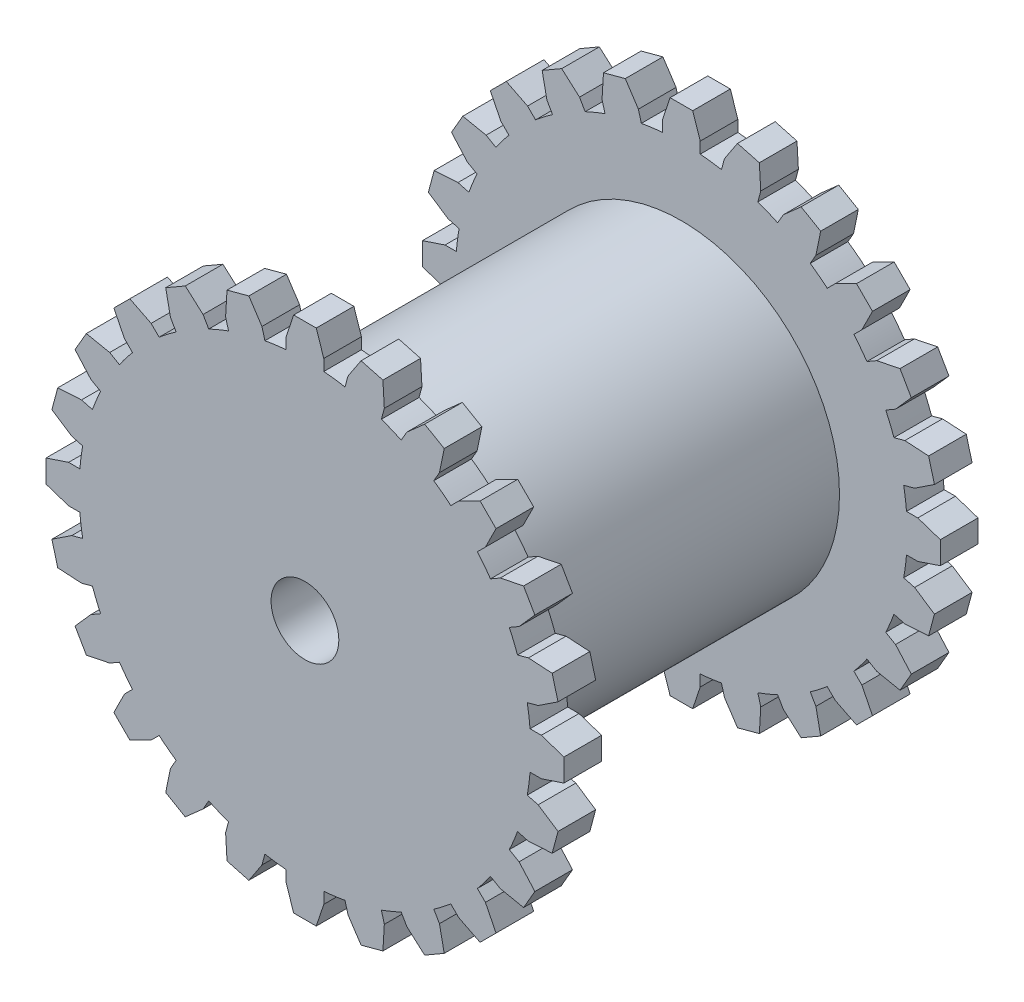
from build123d import *

# Parameters (mm, degrees)
SKETCH1_R           = 30
SKETCH1_R_2         = 4.5
BOSS_EXTRUDE1_DEPTH = 5
BOSS_EXTRUDE2_DEPTH = 5
CIRPATTERN1_COUNT   = 24
SKETCH3_R           = 21
SKETCH3_R_2         = 4.5
BOSS_EXTRUDE5_DEPTH = 22.5


with BuildPart() as part:
    # Sketch1 → Boss-Extrude1 (new body)
    with BuildSketch(Plane.XY):
        Circle(SKETCH1_R)
        Circle(SKETCH1_R_2, mode=Mode.SUBTRACT)
    extrude(amount=BOSS_EXTRUDE1_DEPTH)

    # Sketch2 → Boss-Extrude2 (add)
    with BuildSketch(Plane.XY):
        with BuildLine():
            Line((1.5, 34.395651858), (-1.5, 34.395651858))
            Line((-1.5, 34.395651858), (-2.5, 31.395651858))
            Line((-2.5, 31.395651858), (-2.5, 29.895651858))
            ThreePointArc((-2.5, 29.895651858), (0, 30), (2.5, 29.895651858))
            Line((2.5, 29.895651858), (2.5, 31.395651858))
            Line((2.5, 31.395651858), (1.5, 34.395651858))
        make_face()
    boss_extrude2 = extrude(amount=BOSS_EXTRUDE2_DEPTH)

    # CirPattern1: Boss-Extrude2 ×24 about axis
    cirpattern1_axis = Axis((0, 0, 0), (0, 0, 1))
    for i in range(1, CIRPATTERN1_COUNT):
        add(boss_extrude2.rotate(cirpattern1_axis, i * 360 / CIRPATTERN1_COUNT))

    # Sketch3 → Boss-Extrude5 (add)
    with BuildSketch(Plane.XY):
        Circle(SKETCH3_R)
        Circle(SKETCH3_R_2, mode=Mode.SUBTRACT)
    extrude(amount=-BOSS_EXTRUDE5_DEPTH)

    # Mirror2: part across plane


with BuildPart() as part_1:
    add(part.part)
    add(part.part.mirror(Plane.XY.offset(-22.5)))


solid = part_1.part
